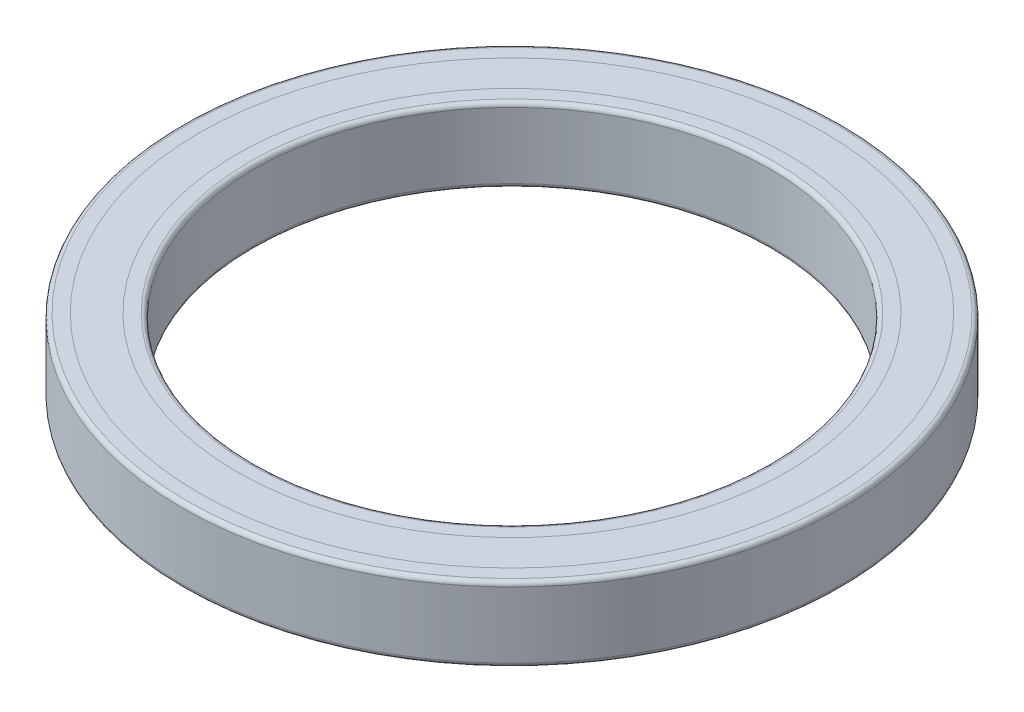
from build123d import *

# Parameters (mm, degrees)
SKETCH1_3_W = 6.5
SKETCH1_3_H = 0.5
FILLET1_R   = 0.75
FILLET2_R   = 0.75


with BuildPart() as part:
    # Sketch1 → Revolve1 (revolve)
    with BuildSketch(Plane.XY):
        with BuildLine():
            Line((45, 6.5), (45, -6.5))
            Line((45, -6.5), (48, -6.5))
            Line((48, -6.5), (48, -6))
            Line((48, -6), (49.25, -6))
            Line((49.25, -6), (49.25, -2.872281323))
            ThreePointArc((49.25, -2.872281323), (47.75, 0), (49.25, 2.872281323))
            Line((49.25, 2.872281323), (49.25, 6))
            Line((49.25, 6), (48, 6))
            Line((48, 6), (48, 6.5))
            Line((48, 6.5), (45, 6.5))
        make_face()
        with BuildLine():
            Line((54.5, -6), (54.5, -6.5))
            Line((54.5, -6.5), (57.5, -6.5))
            Line((57.5, -6.5), (57.5, 6.5))
            Line((57.5, 6.5), (54.5, 6.5))
            Line((54.5, 6.5), (54.5, 6))
            Line((54.5, 6), (53.25, 6))
            Line((53.25, 6), (53.25, 2.872281323))
            ThreePointArc((53.25, 2.872281323), (54.75, 0), (53.25, -2.872281323))
            Line((53.25, -2.872281323), (53.25, -6))
            Line((53.25, -6), (54.5, -6))
        make_face()
    revolve(axis=Axis((0, 0, 0), (0, 1, 0)))

    # Fillet1
    fillet1_edges = [part.edges().sort_by_distance(p)[0] for p in [
        (-45, -6.5, 0),
        (-45, 6.5, 0),
    ]]
    fillet(fillet1_edges, radius=FILLET1_R)

    # Fillet2
    fillet2_edges = [part.edges().sort_by_distance(p)[0] for p in [
        (-57.5, -6.5, 0),
        (-57.5, 6.5, 0),
    ]]
    fillet(fillet2_edges, radius=FILLET2_R)


with BuildPart() as body_2:
    # Sketch1_3 → Revolve2 (revolve)
    with BuildSketch(Plane.XY):
        with Locations((51.25, -6.25)):
            Rectangle(SKETCH1_3_W, SKETCH1_3_H)
        with Locations((51.25, 6.25)):
            Rectangle(SKETCH1_3_W, SKETCH1_3_H)
    revolve(axis=Axis((0, 0, 0), (0, 1, 0)))


solid = Compound([part.part, body_2.part])
